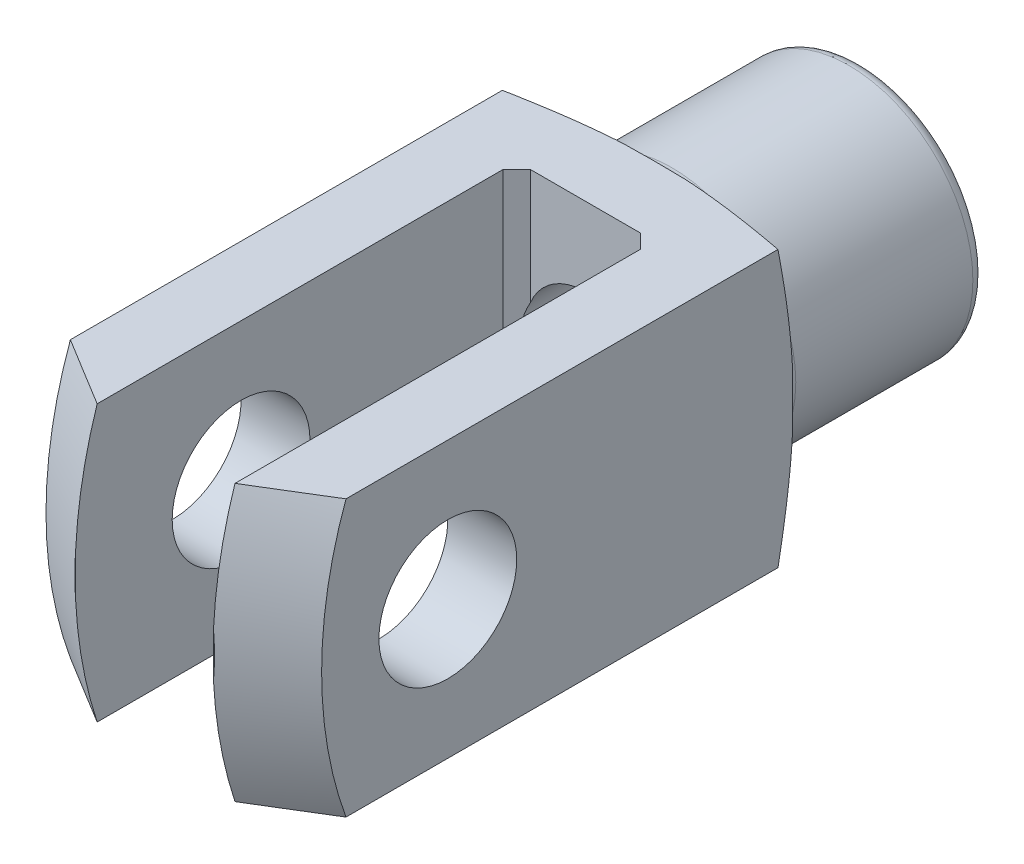
from build123d import *

# Parameters (mm, degrees)
CUT_EXTRUDE1_DEPTH           = 21
CUT_EXTRUDE1_DEPTH_BACK      = 21
CUT_EXTRUDE2_DEPTH           = 21
CUT_EXTRUDE2_DEPTH_BACK      = 21
CUT_EXTRUDE3_DEPTH           = 21
CUT_EXTRUDE3_DEPTH_BACK      = 21
SKETCH5_W                    = 26
SKETCH5_H                    = 5
CUT_REVOLVE3_ANGLE           = 90
CUT_REVOLVE3_OTHER_WAY_ANGLE = 90


with BuildPart() as part:
    # Sketch1 → Revolve1 (revolve)
    with BuildSketch(Plane(origin=(0, 0, 0), x_dir=(0, 0, -1), z_dir=(1, 0, 0))):
        with BuildLine():
            Line((-12, 0), (-12, 20))
            Line((-12, 20), (22.387495374, 20))
            Line((22.387495374, 20), (25, 10.25))
            ThreePointArc((25, 10.25), (25.366116524, 9.366116524), (26.25, 9))
            Line((26.25, 9), (39.1, 9))
            ThreePointArc((39.1, 9), (39.736396103, 8.736396103), (40, 8.1))
            Line((40, 8.1), (40, 0))
            Line((40, 0), (-12, 0))
        make_face()
    revolve(axis=Axis((0, 0, -40), (0, 0, 1)))

    # Sketch2 → Cut-Extrude1 (cut, two sides: drawn at the far end of the back side and taken through both)
    with BuildSketch(Plane(origin=(0, 0, 0), x_dir=(1, 0, 0), z_dir=(0, 1, 0)).offset(-CUT_EXTRUDE1_DEPTH_BACK)):
        Polygon((-5, 19), (-5, -13), (5, -13), (5, 19), (4, 20), (-4, 20), align=None)
    extrude(amount=CUT_EXTRUDE1_DEPTH + CUT_EXTRUDE1_DEPTH_BACK, mode=Mode.SUBTRACT)

    # Sketch3 → Cut-Extrude2 (cut, two sides: drawn at the far end of the back side and taken through both)
    with BuildSketch(Plane(origin=(0, 0, 0), x_dir=(0, 0, -1), z_dir=(1, 0, 0)).offset(-CUT_EXTRUDE2_DEPTH_BACK)):
        Polygon((-33, -30), (40, -30), (40, -10), (-13, -10), (-13, 10), (40, 10), (40, 30), (-33, 30), align=None)
    extrude(amount=CUT_EXTRUDE2_DEPTH + CUT_EXTRUDE2_DEPTH_BACK, mode=Mode.SUBTRACT)

    # Sketch4 → Cut-Extrude3 (cut, two sides: drawn at the far end of the back side and taken through both)
    with BuildSketch(Plane(origin=(0, 0, 0), x_dir=(1, 0, 0), z_dir=(0, 1, 0)).offset(-CUT_EXTRUDE3_DEPTH_BACK)):
        Polygon((-30, -33), (30, -33), (30, 40), (10, 40), (10, -13), (-10, -13), (-10, 40), (-30, 40), align=None)
    extrude(amount=CUT_EXTRUDE3_DEPTH + CUT_EXTRUDE3_DEPTH_BACK, mode=Mode.SUBTRACT)

    # Sketch5 → Cut-Revolve1 (revolve, cut)
    with BuildSketch(Plane.XY):
        with Locations((0, 2.5)):
            Rectangle(SKETCH5_W, SKETCH5_H)
    revolve(axis=Axis((13, 0, 0), (-1, 0, 0)), mode=Mode.SUBTRACT)

    # Sketch6 → Cut-Revolve2 (revolve, cut)
    with BuildSketch(Plane(origin=(0, 0, 0), x_dir=(0, 0, -1), z_dir=(1, 0, 0))):
        Polygon((18.9, 0), (18.9, 4.3235), (39.4235, 4.3235), (40.1, 5), (40.1, 0), align=None)
    revolve(axis=Axis((0, 0, -40.1), (0, 0, 1)), mode=Mode.SUBTRACT)

    # Sketch7 → Cut-Revolve3 (revolve, cut)
    with BuildSketch(Plane(origin=(0, 0, 0), x_dir=(1, 0, 0), z_dir=(0, 1, 0))):
        Polygon((-12, -8.000813089), (-12, -31.094823856), (0, -38.023027087), (12, -31.094823856), (12, -8.000813089), (0, -14.929016319), align=None)
    revolve(axis=Axis((-12, 0, -20), (-1, 0, 0)), revolution_arc=CUT_REVOLVE3_ANGLE, mode=Mode.SUBTRACT)

    # Sketch7 → Cut-Revolve3 other way (revolve, cut)
    with BuildSketch(Plane(origin=(0, 0, 0), x_dir=(1, 0, 0), z_dir=(0, 1, 0))):
        Polygon((-12, -8.000813089), (-12, -31.094823856), (0, -38.023027087), (12, -31.094823856), (12, -8.000813089), (0, -14.929016319), align=None)
    revolve(axis=Axis((-12, 0, -20), (1, 0, 0)), revolution_arc=CUT_REVOLVE3_OTHER_WAY_ANGLE, mode=Mode.SUBTRACT)


solid = part.part
